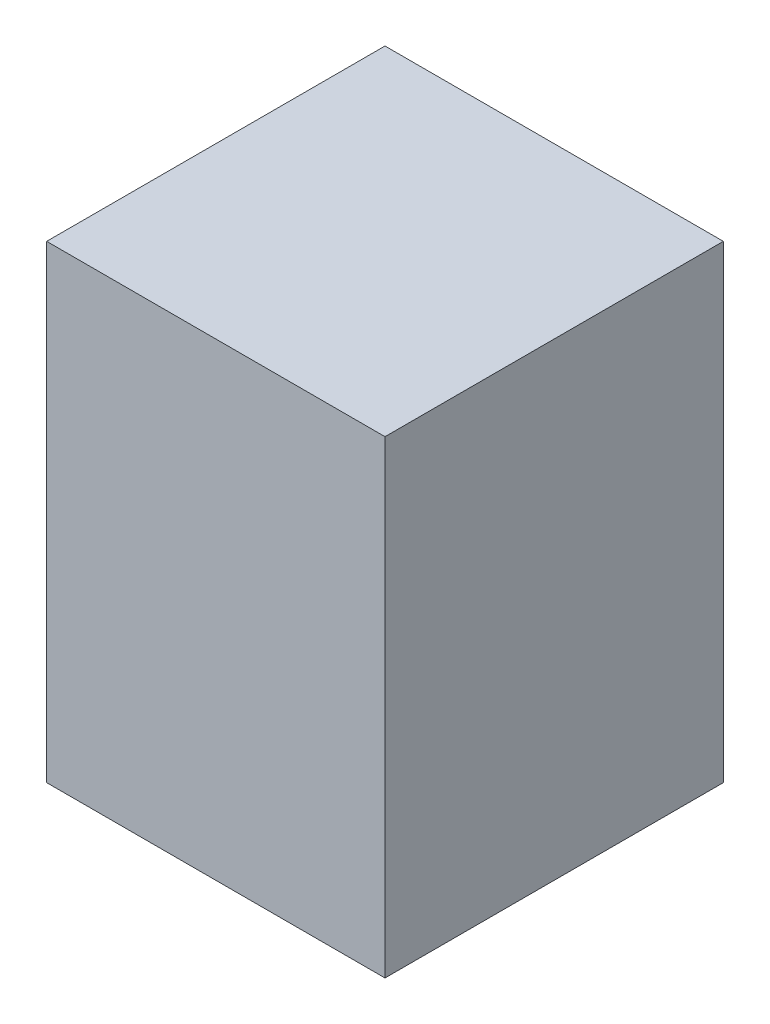
from build123d import *

# Parameters (mm, degrees)
SKETCH1_W           = 9.75
SKETCH1_H           = 9.75
BOSS_EXTRUDE1_DEPTH = 13.51


with BuildPart() as part:
    # Sketch1 → Boss-Extrude1 (new body)
    with BuildSketch(Plane(origin=(0, 0, 0), x_dir=(1, 0, 0), z_dir=(0, 1, 0))):
        with Locations((-4.875, -4.875)):
            Rectangle(SKETCH1_W, SKETCH1_H)
    extrude(amount=BOSS_EXTRUDE1_DEPTH)


solid = part.part
